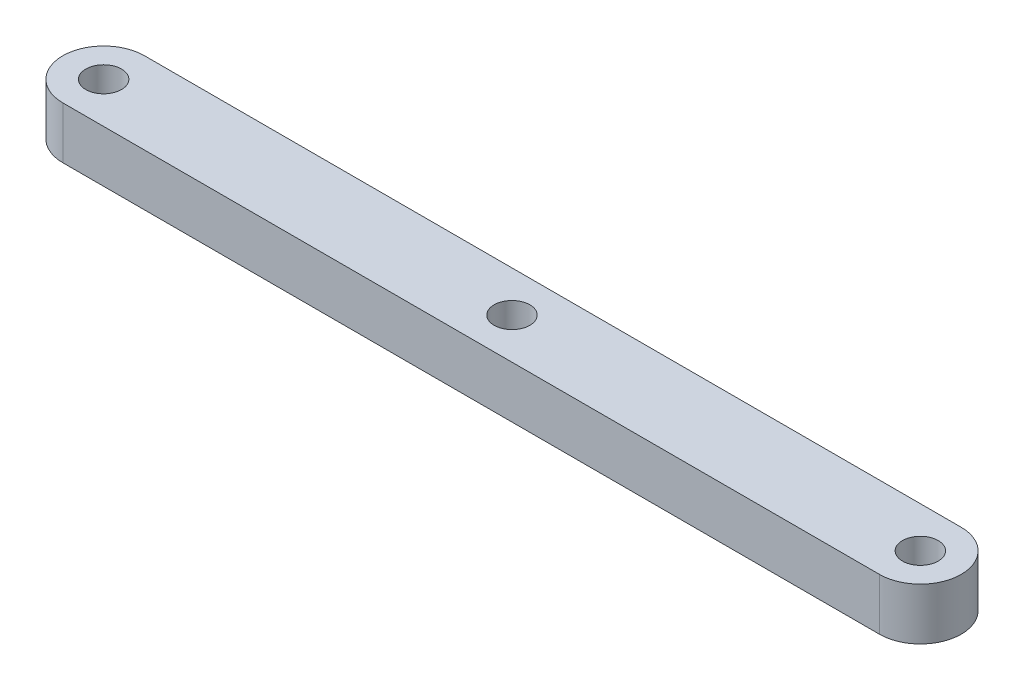
from build123d import *

# Parameters (mm, degrees)
SKETCH1_R           = 1.0922
BOSS_EXTRUDE1_DEPTH = 3.175


with BuildPart() as part:
    # Sketch1 → Boss-Extrude1 (new body)
    with BuildSketch(Plane(origin=(0, 0, 0), x_dir=(1, 0, 0), z_dir=(0, 1, 0))):
        with BuildLine():
            Line((-10.021786492, 6.524141437), (39.978213508, 6.524141437))
            ThreePointArc((39.978213508, 6.524141437), (42.478213508, 4.024141437), (39.978213508, 1.524141437))
            Line((39.978213508, 1.524141437), (-10.021786492, 1.524141437))
            ThreePointArc((-10.021786492, 1.524141437), (-12.521786492, 4.024141437), (-10.021786492, 6.524141437))
        make_face()
        with Locations((-10.021786492, 4.024141437)):
            Circle(SKETCH1_R, mode=Mode.SUBTRACT)
        with Locations((39.978213508, 4.024141437)):
            Circle(SKETCH1_R, mode=Mode.SUBTRACT)
        with Locations((14.978213508, 4.024141437)):
            Circle(SKETCH1_R, mode=Mode.SUBTRACT)
    extrude(amount=BOSS_EXTRUDE1_DEPTH)


solid = part.part
